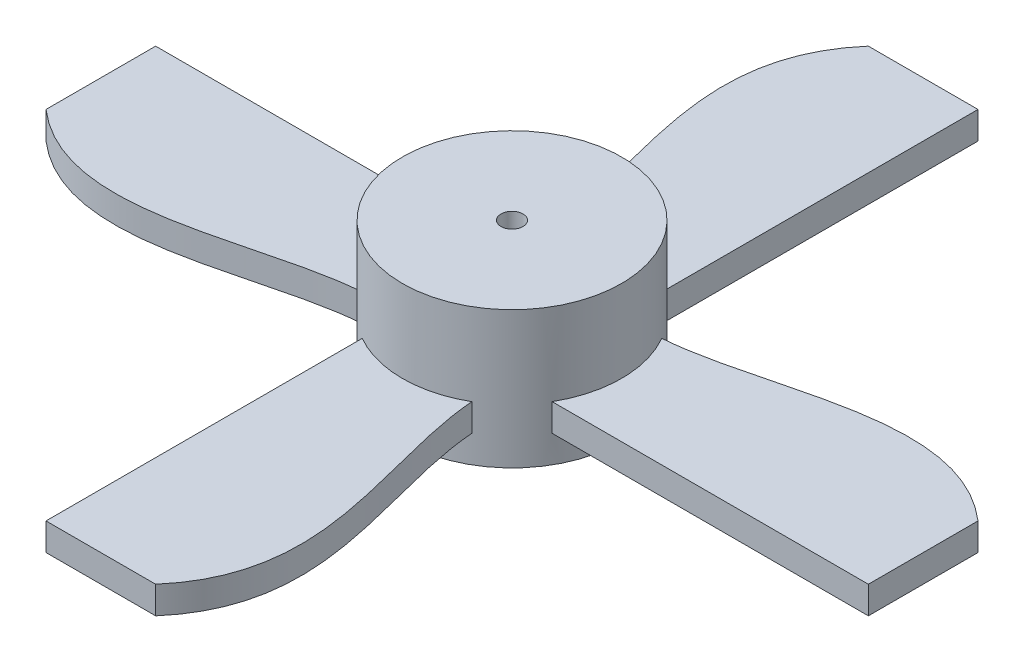
from build123d import *

# Parameters (mm, degrees)
SKETCH1_R               = 4
BOSS_EXTRUDE1_DEPTH     = 5
BOSS_EXTRUDE2_START     = 1
BOSS_EXTRUDE2_DEPTH     = 1
SKETCH3_R               = 0.4
CUT_EXTRUDE1_DEPTH      = 1
CUT_EXTRUDE1_DEPTH_BACK = 6


with BuildPart() as part:
    # Sketch1 → Boss-Extrude1 (new body)
    with BuildSketch(Plane(origin=(0, 0, 0), x_dir=(1, 0, 0), z_dir=(0, 1, 0))):
        Circle(SKETCH1_R)
    extrude(amount=BOSS_EXTRUDE1_DEPTH)

    # Sketch2 → Boss-Extrude2 (add)
    with BuildSketch(Plane(origin=(0, 0, 0), x_dir=(1, 0, 0), z_dir=(0, 1, 0)).offset(BOSS_EXTRUDE2_START)):
        with BuildLine():
            Line((15, -2), (3.464101615, -2))
            ThreePointArc((3.464101615, -2), (4, 0), (3.464101615, 2))
            add(Edge.make_bspline(
                [(3.464101615, 2), (7.059911859, 2.261875705), (11.549393059, 4.995376959), (15, 2)],
                knots=[0, 0, 0, 0, 1, 1, 1, 1], degree=3))
            Line((15, 2), (15, 0))
            Line((15, 0), (15, -2))
        make_face()
        with BuildLine():
            Line((2, -15), (0, -15))
            Line((0, -15), (-2, -15))
            Line((-2, -15), (-2, -3.464101615))
            ThreePointArc((-2, -3.464101615), (0, -4), (2, -3.464101615))
            add(Edge.make_bspline(
                [(2, -3.464101615), (2.261875705, -7.059911859), (4.995376959, -11.549393059), (2, -15)],
                knots=[0, 0, 0, 0, 1, 1, 1, 1], degree=3))
        make_face()
        with BuildLine():
            Line((-15, -2), (-15, 0))
            Line((-15, 0), (-15, 2))
            Line((-15, 2), (-3.464101615, 2))
            ThreePointArc((-3.464101615, 2), (-4, 0), (-3.464101615, -2))
            add(Edge.make_bspline(
                [(-3.464101615, -2), (-7.059911859, -2.261875705), (-11.549393059, -4.995376959), (-15, -2)],
                knots=[0, 0, 0, 0, 1, 1, 1, 1], degree=3))
        make_face()
        with BuildLine():
            Line((-2, 15), (0, 15))
            Line((0, 15), (2, 15))
            Line((2, 15), (2, 3.464101615))
            ThreePointArc((2, 3.464101615), (0, 4), (-2, 3.464101615))
            add(Edge.make_bspline(
                [(-2, 3.464101615), (-2.261875705, 7.059911859), (-4.995376959, 11.549393059), (-2, 15)],
                knots=[0, 0, 0, 0, 1, 1, 1, 1], degree=3))
        make_face()
    extrude(amount=BOSS_EXTRUDE2_DEPTH)

    # Sketch3 → Cut-Extrude1 (cut, two sides)
    with BuildSketch(Plane(origin=(0, 5, 0), x_dir=(1, 0, 0), z_dir=(0, 1, 0))) as cut_extrude1_sk:
        Circle(SKETCH3_R)
    extrude(amount=CUT_EXTRUDE1_DEPTH, mode=Mode.SUBTRACT)
    extrude(cut_extrude1_sk.sketch, amount=-CUT_EXTRUDE1_DEPTH_BACK, mode=Mode.SUBTRACT)


solid = part.part
